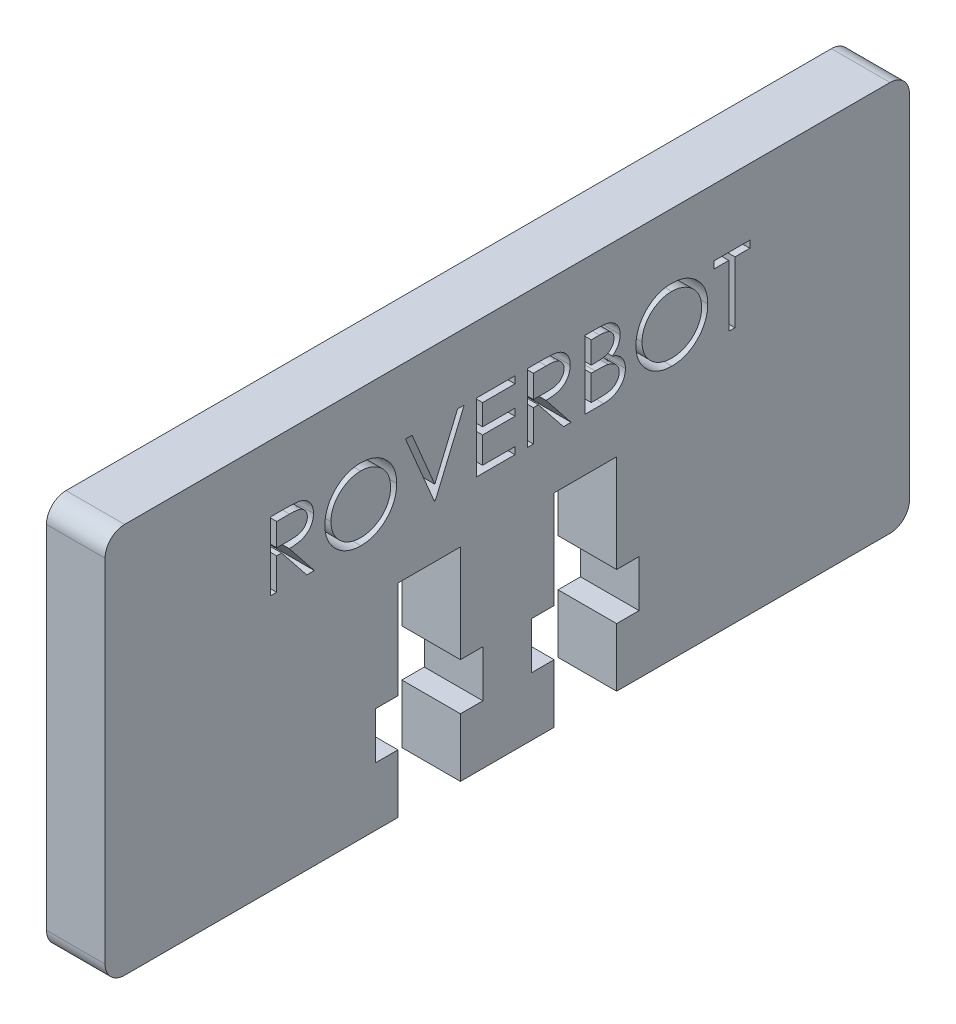
from build123d import *

# Parameters (mm, degrees)
BOSS_EXTRUDE1_DEPTH = 3
FILLET1_R           = 1
CUT_EXTRUDE1_DEPTH  = 4


with BuildPart() as part:
    # Sketch1 → Boss-Extrude1 (new body)
    with BuildSketch(Plane(origin=(0, 0, 0), x_dir=(0, 0, -1), z_dir=(1, 0, 0))):
        Polygon((-5.6, 0), (-5.6, 3), (-6.75, 3), (-6.75, 5.4), (-5.6, 5.4), (-5.6, 10.4), (-2.4, 10.4), (-2.4, 5.4), (-1.25, 5.4), (-1.25, 3), (-2.4, 3), (-2.4, 0), (2.4, 0), (2.4, 3), (1.25, 3), (1.25, 5.4), (2.4, 5.4), (2.4, 10.4), (5.6, 10.4), (5.6, 5.4), (6.75, 5.4), (6.75, 3), (5.6, 3), (5.6, 0), (20.6, 0), (20.6, 20), (-20.6, 20), (-20.6, 0), align=None)
    extrude(amount=BOSS_EXTRUDE1_DEPTH)

    # Fillet1
    fillet1_edges = [part.edges().sort_by_distance(p)[0] for p in [
        (1.5, 0, 20.6),
        (1.5, 20, 20.6),
        (1.5, 20, -20.6),
        (1.5, 0, -20.6),
    ]]
    fillet(fillet1_edges, radius=FILLET1_R)

    # Sketch2 → Cut-Extrude1 (cut, through all)
    with BuildSketch(Plane(origin=(3, 0, 0), x_dir=(0, 0, -1), z_dir=(1, 0, 0))):
        with BuildLine():
            Line((-12.124529254, 16.594452032), (-11.424108581, 16.594452032))
            add(Edge.make_bspline(
                [(-11.424108581, 16.594452032), (-11.377367453, 16.594296446), (-11.287619308, 16.593997704), (-11.159046038, 16.592331941), (-11.042218941, 16.587557585), (-10.937199102, 16.583449001), (-10.843988447, 16.57595706), (-10.762301156, 16.568796413), (-10.692513459, 16.559422752), (-10.650267607, 16.550717329), (-10.631139831, 16.54677575)],
                knots=[0, 0, 0, 0, 0.000140226, 0.00026925, 0.000385712, 0.000490995, 0.000584507, 0.000666202, 0.000736998, 0.000795574, 0.000795574, 0.000795574, 0.000795574], degree=3))
            add(Edge.make_bspline(
                [(-10.631139831, 16.54677575), (-10.605533207, 16.540448984), (-10.554866218, 16.527930421), (-10.481916152, 16.50147082), (-10.412401828, 16.470851195), (-10.346612003, 16.434887475), (-10.284876212, 16.393312695), (-10.226557901, 16.346844573), (-10.171392438, 16.295737367), (-10.121610808, 16.238702526), (-10.074671756, 16.178866016), (-10.03508313, 16.114162259), (-10.00095665, 16.046500732), (-9.973786133, 15.975193314), (-9.95190816, 15.900931542), (-9.93648192, 15.823042745), (-9.927230733, 15.74188177), (-9.926288877, 15.686523861), (-9.925811306, 15.658454436)],
                knots=[0, 0, 0, 0, 7.9081e-05, 0.000156475, 0.000232432, 0.000306798, 0.00038108, 0.000455429, 0.000530331, 0.000606314, 0.000682321, 0.000758201, 0.000833453, 0.000909362, 0.000986794, 0.001065445, 0.001147284, 0.001231465, 0.001231465, 0.001231465, 0.001231465], degree=3))
            add(Edge.make_bspline(
                [(-9.925811306, 15.658454436), (-9.927280304, 15.611819331), (-9.9301467, 15.520822163), (-9.956871803, 15.388761282), (-10.000648323, 15.265571967), (-10.060971612, 15.151409329), (-10.137791088, 15.048498684), (-10.230115879, 14.958108229), (-10.33799749, 14.882468316), (-10.438426806, 14.830015511), (-10.527141006, 14.796422603), (-10.600174319, 14.772786244), (-10.679841296, 14.754524279), (-10.765378631, 14.738164147), (-10.857142286, 14.725812452), (-10.954912326, 14.716765858), (-11.058758477, 14.711111809), (-11.130097547, 14.710269804), (-11.166796883, 14.709836647)],
                knots=[0, 0, 0, 0, 0.000139777, 0.000272741, 0.000402249, 0.000530843, 0.000658588, 0.000786009, 0.000916741, 0.001052522, 0.001124656, 0.001201155, 0.001282612, 0.001369656, 0.001462366, 0.001560247, 0.001664165, 0.001774261, 0.001774261, 0.001774261, 0.001774261], degree=3))
            Line((-11.166796883, 14.709836647), (-9.880939511, 13.094452032))
            Line((-9.880939511, 13.094452032), (-10.269360985, 13.094452032))
            Line((-10.269360985, 13.094452032), (-11.555218357, 14.709836647))
            Line((-11.555218357, 14.709836647), (-11.81042669, 14.709836647))
            Line((-11.81042669, 14.709836647), (-11.81042669, 13.094452032))
            Line((-11.81042669, 13.094452032), (-12.124529254, 13.094452032))
            Line((-12.124529254, 13.094452032), (-12.124529254, 16.594452032))
        make_face()
        with BuildLine():
            Line((-11.81042669, 16.235477673), (-11.81042669, 15.068811006))
            Line((-11.81042669, 15.068811006), (-11.16960137, 15.063903154))
            add(Edge.make_bspline(
                [(-11.16960137, 15.063903154), (-11.139681331, 15.063889917), (-11.081687774, 15.063864261), (-10.997787109, 15.067858037), (-10.919666997, 15.072401355), (-10.847626245, 15.079350701), (-10.78163267, 15.088306772), (-10.721719257, 15.099509757), (-10.667788205, 15.112561819), (-10.604889666, 15.132763445), (-10.534653135, 15.164769463), (-10.458321675, 15.211334962), (-10.393319337, 15.269904081), (-10.338401475, 15.336877537), (-10.294272043, 15.410513786), (-10.263159989, 15.489930155), (-10.243417547, 15.573121753), (-10.241089001, 15.630299861), (-10.23991387, 15.659155558)],
                knots=[0, 0, 0, 0, 8.9746e-05, 0.000173954, 0.000251933, 0.000324488, 0.000391021, 0.000451663, 0.000507268, 0.000557378, 0.000649639, 0.000738152, 0.000824558, 0.000910739, 0.000997194, 0.001080909, 0.00116578, 0.001252248, 0.001252248, 0.001252248, 0.001252248], degree=3))
            add(Edge.make_bspline(
                [(-10.23991387, 15.659155558), (-10.241115991, 15.687302131), (-10.243498156, 15.74307837), (-10.262946925, 15.82473428), (-10.295836306, 15.90180123), (-10.340158544, 15.973965715), (-10.394157699, 16.039471451), (-10.457475512, 16.095518604), (-10.528380707, 16.141768069), (-10.594651905, 16.171322449), (-10.653886118, 16.189442303), (-10.705315778, 16.202193466), (-10.763427255, 16.212437935), (-10.828502714, 16.220645996), (-10.900264345, 16.227700941), (-10.979074996, 16.232452719), (-11.064411776, 16.235266583), (-11.123558707, 16.235405672), (-11.15417669, 16.235477673)],
                knots=[0, 0, 0, 0, 8.4371e-05, 0.000167192, 0.000250141, 0.000334794, 0.000420435, 0.000503871, 0.000587493, 0.000673488, 0.0007205, 0.000773215, 0.000832351, 0.0008974, 0.000969955, 0.001048634, 0.001134217, 0.001226067, 0.001226067, 0.001226067, 0.001226067], degree=3))
            Line((-11.15417669, 16.235477673), (-11.81042669, 16.235477673))
        make_face(mode=Mode.SUBTRACT)
        with BuildLine():
            add(Edge.make_bspline(
                [(-7.52517028, 16.684195622), (-7.460362174, 16.682554142), (-7.333073707, 16.679330141), (-7.145998809, 16.654651038), (-6.967403714, 16.611955648), (-6.795833575, 16.555092665), (-6.633340599, 16.47923828), (-6.478701706, 16.387553132), (-6.332284833, 16.279076673), (-6.196063451, 16.154647446), (-6.071406501, 16.019263992), (-5.961580614, 15.874786082), (-5.869538321, 15.72208728), (-5.793952534, 15.561626449), (-5.734653924, 15.393766481), (-5.69373488, 15.217612478), (-5.66759673, 15.034305788), (-5.664540953, 14.909278924), (-5.662990793, 14.845854275)],
                knots=[0, 0, 0, 0, 0.000194393, 0.000381804, 0.00056479, 0.000744601, 0.000923091, 0.001101652, 0.001283106, 0.001468738, 0.001654324, 0.001834514, 0.002012231, 0.002188181, 0.002365797, 0.002545211, 0.002729936, 0.002920126, 0.002920126, 0.002920126, 0.002920126], degree=3))
            add(Edge.make_bspline(
                [(-5.662990793, 14.845854275), (-5.664540725, 14.782896829), (-5.667595822, 14.658800409), (-5.6937646, 14.476656964), (-5.734805599, 14.301566268), (-5.793401866, 14.133820615), (-5.868627344, 13.973243051), (-5.961282515, 13.820256098), (-6.070423726, 13.674809599), (-6.194630577, 13.538496934), (-6.330031619, 13.413499463), (-6.475261886, 13.304580588), (-6.627055206, 13.210856463), (-6.787364914, 13.136072789), (-6.954064951, 13.076300869), (-7.128647274, 13.035548239), (-7.310293828, 13.009261195), (-7.434164832, 13.006242679), (-7.497125408, 13.004708442)],
                knots=[0, 0, 0, 0, 0.000188789, 0.000372126, 0.000550857, 0.00072758, 0.000904164, 0.001081881, 0.001263191, 0.001448823, 0.00163441, 0.001815159, 0.001992641, 0.002168591, 0.002344885, 0.002522934, 0.002705576, 0.002894365, 0.002894365, 0.002894365, 0.002894365], degree=3))
            add(Edge.make_bspline(
                [(-7.497125408, 13.004708442), (-7.560549727, 13.006257829), (-7.685575943, 13.009312083), (-7.869112979, 13.035493488), (-8.045390722, 13.076434792), (-8.213905074, 13.134944228), (-8.374750003, 13.210561458), (-8.528240086, 13.302765838), (-8.673759233, 13.412172979), (-8.81010098, 13.536339553), (-8.934850178, 13.671511105), (-9.043609554, 13.81634536), (-9.135834667, 13.968000817), (-9.211197999, 14.126898341), (-9.270862459, 14.292269784), (-9.311567277, 14.465218261), (-9.337903229, 14.644757767), (-9.340938075, 14.767000665), (-9.342477972, 14.829027352)],
                knots=[0, 0, 0, 0, 0.00019019, 0.000374915, 0.000555011, 0.000732396, 0.00090898, 0.001087298, 0.001268608, 0.00145424, 0.001639827, 0.001819595, 0.001996712, 0.002171394, 0.002346367, 0.002523053, 0.002703612, 0.002889599, 0.002889599, 0.002889599, 0.002889599], degree=3))
            add(Edge.make_bspline(
                [(-9.342477972, 14.829027352), (-9.341943337, 14.870660022), (-9.340880811, 14.953400145), (-9.328089118, 15.076266745), (-9.309527417, 15.197157403), (-9.282925504, 15.315728351), (-9.248133837, 15.431689336), (-9.20708181, 15.545840098), (-9.156941965, 15.657023822), (-9.100261317, 15.765767214), (-9.036999509, 15.87037512), (-8.967123759, 15.969254703), (-8.893088391, 16.0632357), (-8.811924997, 16.149882704), (-8.726308552, 16.23171636), (-8.634850174, 16.307479077), (-8.538107929, 16.377854028), (-8.43566555, 16.441274369), (-8.330047275, 16.498633504), (-8.221170497, 16.547855355), (-8.110513925, 16.590101416), (-7.997559277, 16.624342241), (-7.882606505, 16.651374277), (-7.765404721, 16.669781631), (-7.646047294, 16.682605949), (-7.565635976, 16.683663451), (-7.52517028, 16.684195622)],
                knots=[0, 0, 0, 0, 0.000124849, 0.000248123, 0.000370193, 0.00049164, 0.000612319, 0.000733199, 0.000855287, 0.000977905, 0.001100913, 0.001221706, 0.001340948, 0.001459521, 0.001577551, 0.001696047, 0.001815534, 0.001936153, 0.002057243, 0.002175846, 0.002294342, 0.002412335, 0.002529682, 0.00264829, 0.002768075, 0.00288942, 0.00288942, 0.00288942, 0.00288942], degree=3))
        make_face()
        with BuildLine():
            add(Edge.make_bspline(
                [(-7.509745601, 16.325221263), (-7.542960234, 16.324816372), (-7.609071967, 16.324010463), (-7.707356503, 16.313394747), (-7.804348437, 16.298264858), (-7.900067799, 16.276683337), (-7.994114089, 16.247279285), (-8.08736393, 16.213438376), (-8.178966984, 16.172217286), (-8.268620842, 16.125644581), (-8.355535917, 16.074095661), (-8.437548618, 16.017123894), (-8.514871262, 15.956065339), (-8.587314529, 15.890777502), (-8.654665701, 15.8209279), (-8.718250402, 15.747575464), (-8.775519984, 15.668623573), (-8.828005561, 15.586213166), (-8.874973401, 15.500451585), (-8.916738756, 15.412241723), (-8.950902765, 15.320864036), (-8.978765141, 15.227309878), (-9.001864952, 15.131727419), (-9.016498876, 15.03339157), (-9.027231235, 14.932796458), (-9.027991081, 14.864814604), (-9.028375408, 14.830429596)],
                knots=[0, 0, 0, 0, 9.9599e-05, 0.000198245, 0.000296222, 0.00039402, 0.00049227, 0.000591646, 0.000691452, 0.000793368, 0.000894612, 0.000994383, 0.001092713, 0.00119001, 0.001286696, 0.001383657, 0.001480979, 0.001579008, 0.001676595, 0.001774142, 0.001871547, 0.001968922, 0.002066879, 0.00216624, 0.00226698, 0.002370083, 0.002370083, 0.002370083, 0.002370083], degree=3))
            add(Edge.make_bspline(
                [(-9.028375408, 14.830429596), (-9.027100546, 14.779867375), (-9.024592498, 14.680395845), (-9.002634928, 14.534627701), (-8.968812954, 14.394539415), (-8.918955587, 14.260897505), (-8.856604973, 14.132553223), (-8.779578083, 14.010645118), (-8.688318997, 13.895140243), (-8.58465547, 13.786844975), (-8.471332764, 13.68799917), (-8.351000034, 13.601235762), (-8.224946426, 13.527825512), (-8.092843224, 13.468020439), (-7.955395685, 13.420630702), (-7.811718134, 13.388152071), (-7.662767674, 13.366776615), (-7.561237019, 13.364723859), (-7.509745601, 13.363682801)],
                knots=[0, 0, 0, 0, 0.000151605, 0.000298253, 0.000441263, 0.000583229, 0.000725274, 0.000868635, 0.001014928, 0.001166177, 0.001317744, 0.00146543, 0.001610576, 0.001754594, 0.001899821, 0.002045914, 0.002195936, 0.002350312, 0.002350312, 0.002350312, 0.002350312], degree=3))
            add(Edge.make_bspline(
                [(-7.509745601, 13.363682801), (-7.475136099, 13.364158305), (-7.406495063, 13.365101373), (-7.30439954, 13.37460005), (-7.204143329, 13.38983192), (-7.105867049, 13.411762575), (-7.009682237, 13.439209782), (-6.915187434, 13.47181751), (-6.823389144, 13.512498713), (-6.733129306, 13.557446665), (-6.646733064, 13.608686822), (-6.564257532, 13.663724972), (-6.487781552, 13.724693593), (-6.415392481, 13.789011405), (-6.347764792, 13.857975253), (-6.285355808, 13.931495475), (-6.228375675, 14.010036132), (-6.175910029, 14.092321538), (-6.129106766, 14.178317791), (-6.088327667, 14.266847469), (-6.053731551, 14.357692578), (-6.025803046, 14.45098415), (-6.003917585, 14.546544998), (-5.988837665, 14.644503076), (-5.978289226, 14.744662419), (-5.977494149, 14.812406275), (-5.977093357, 14.846555397)],
                knots=[0, 0, 0, 0, 0.000103804, 0.000205874, 0.000307314, 0.000407849, 0.000507719, 0.000607281, 0.000707445, 0.000808723, 0.000909609, 0.001008589, 0.001105934, 0.001202762, 0.001298946, 0.001395452, 0.001491794, 0.001589823, 0.001688026, 0.001785277, 0.001882027, 0.001979402, 0.0020772, 0.002175869, 0.002276609, 0.002379011, 0.002379011, 0.002379011, 0.002379011], degree=3))
            add(Edge.make_bspline(
                [(-5.977093357, 14.846555397), (-5.97749447, 14.880470902), (-5.978290151, 14.947748552), (-5.988832626, 15.04720937), (-6.003933516, 15.144462582), (-6.025696224, 15.239126385), (-6.053746378, 15.33122491), (-6.088333709, 15.420671657), (-6.129119008, 15.507799852), (-6.175927232, 15.592394149), (-6.228543056, 15.673568887), (-6.286037299, 15.7511713), (-6.349402647, 15.823744041), (-6.416828672, 15.893078735), (-6.489999558, 15.957696625), (-6.568583852, 16.017619146), (-6.651627529, 16.07429242), (-6.739554765, 16.125417982), (-6.830298719, 16.172632214), (-6.923412677, 16.213083217), (-7.017841776, 16.247455337), (-7.113345889, 16.276772302), (-7.210728867, 16.298180332), (-7.309332696, 16.313408382), (-7.409020954, 16.324006768), (-7.476064174, 16.324815146), (-7.509745601, 16.325221263)],
                knots=[0, 0, 0, 0, 0.000101701, 0.000201743, 0.00029972, 0.000396835, 0.000492868, 0.000588308, 0.000684288, 0.000781261, 0.000878109, 0.000974304, 0.001070733, 0.001166917, 0.001264269, 0.001363274, 0.001463228, 0.001565678, 0.001668217, 0.001769947, 0.001869982, 0.001969573, 0.002069423, 0.002168785, 0.002268827, 0.002369827, 0.002369827, 0.002369827, 0.002369827], degree=3))
        make_face(mode=Mode.SUBTRACT)
        Polygon((-5.214272844, 16.594452032), (-4.877734383, 16.594452032), (-3.711067716, 13.836238891), (-2.544401049, 16.594452032), (-2.207862588, 16.594452032), (-3.688631819, 13.094452032), (-3.733503613, 13.094452032), align=None)
        Polygon((-1.57965746, 16.594452032), (0.394701515, 16.594452032), (0.394701515, 16.235477673), (-1.265554895, 16.235477673), (-1.265554895, 15.158554596), (0.394701515, 15.158554596), (0.394701515, 14.799580237), (-1.265554895, 14.799580237), (-1.265554895, 13.453426391), (0.394701515, 13.453426391), (0.394701515, 13.094452032), (-1.57965746, 13.094452032), align=None)
        with BuildLine():
            Line((1.022906643, 16.594452032), (1.723327316, 16.594452032))
            add(Edge.make_bspline(
                [(1.723327316, 16.594452032), (1.770068445, 16.594296446), (1.859816589, 16.593997704), (1.988389859, 16.592331941), (2.105216956, 16.587557585), (2.210236796, 16.583449001), (2.303447451, 16.57595706), (2.385134741, 16.568796413), (2.454922439, 16.559422752), (2.49716829, 16.550717329), (2.516296066, 16.54677575)],
                knots=[0, 0, 0, 0, 0.000140226, 0.00026925, 0.000385712, 0.000490995, 0.000584507, 0.000666202, 0.000736998, 0.000795574, 0.000795574, 0.000795574, 0.000795574], degree=3))
            add(Edge.make_bspline(
                [(2.516296066, 16.54677575), (2.54190269, 16.540448984), (2.59256968, 16.527930421), (2.665519746, 16.50147082), (2.73503407, 16.470851195), (2.800823894, 16.434887475), (2.862559685, 16.393312695), (2.920877996, 16.346844573), (2.976043459, 16.295737367), (3.02582509, 16.238702526), (3.072764141, 16.178866016), (3.112352768, 16.114162259), (3.146479247, 16.046500732), (3.173649764, 15.975193314), (3.195527738, 15.900931542), (3.210953977, 15.823042745), (3.220205165, 15.74188177), (3.22114702, 15.686523861), (3.221624592, 15.658454436)],
                knots=[0, 0, 0, 0, 7.9081e-05, 0.000156475, 0.000232432, 0.000306798, 0.00038108, 0.000455429, 0.000530331, 0.000606314, 0.000682321, 0.000758201, 0.000833453, 0.000909362, 0.000986794, 0.001065445, 0.001147284, 0.001231465, 0.001231465, 0.001231465, 0.001231465], degree=3))
            add(Edge.make_bspline(
                [(3.221624592, 15.658454436), (3.220155594, 15.611819331), (3.217289198, 15.520822163), (3.190564094, 15.388761282), (3.146787574, 15.265571967), (3.086464285, 15.151409329), (3.00964481, 15.048498684), (2.917320019, 14.958108229), (2.809438407, 14.882468316), (2.709009091, 14.830015511), (2.620294891, 14.796422603), (2.547261579, 14.772786244), (2.467594601, 14.754524279), (2.382057267, 14.738164147), (2.290293611, 14.725812452), (2.192523572, 14.716765858), (2.08867742, 14.711111809), (2.017338351, 14.710269804), (1.980639015, 14.709836647)],
                knots=[0, 0, 0, 0, 0.000139777, 0.000272741, 0.000402249, 0.000530843, 0.000658588, 0.000786009, 0.000916741, 0.001052522, 0.001124656, 0.001201155, 0.001282612, 0.001369656, 0.001462366, 0.001560247, 0.001664165, 0.001774261, 0.001774261, 0.001774261, 0.001774261], degree=3))
            Line((1.980639015, 14.709836647), (3.266496387, 13.094452032))
            Line((3.266496387, 13.094452032), (2.878074912, 13.094452032))
            Line((2.878074912, 13.094452032), (1.59221754, 14.709836647))
            Line((1.59221754, 14.709836647), (1.337009207, 14.709836647))
            Line((1.337009207, 14.709836647), (1.337009207, 13.094452032))
            Line((1.337009207, 13.094452032), (1.022906643, 13.094452032))
            Line((1.022906643, 13.094452032), (1.022906643, 16.594452032))
        make_face()
        with BuildLine():
            Line((1.337009207, 16.235477673), (1.337009207, 15.068811006))
            Line((1.337009207, 15.068811006), (1.977834528, 15.063903154))
            add(Edge.make_bspline(
                [(1.977834528, 15.063903154), (2.007754567, 15.063889917), (2.065748124, 15.063864261), (2.149648788, 15.067858037), (2.2277689, 15.072401355), (2.299809652, 15.079350701), (2.365803228, 15.088306772), (2.425716641, 15.099509757), (2.479647693, 15.112561819), (2.542546231, 15.132763445), (2.612782763, 15.164769463), (2.689114222, 15.211334962), (2.75411656, 15.269904081), (2.809034422, 15.336877537), (2.853163854, 15.410513786), (2.884275908, 15.489930155), (2.904018351, 15.573121753), (2.906346896, 15.630299861), (2.907522028, 15.659155558)],
                knots=[0, 0, 0, 0, 8.9746e-05, 0.000173954, 0.000251933, 0.000324488, 0.000391021, 0.000451663, 0.000507268, 0.000557378, 0.000649639, 0.000738152, 0.000824558, 0.000910739, 0.000997194, 0.001080909, 0.00116578, 0.001252248, 0.001252248, 0.001252248, 0.001252248], degree=3))
            add(Edge.make_bspline(
                [(2.907522028, 15.659155558), (2.906319907, 15.687302131), (2.903937741, 15.74307837), (2.884488973, 15.82473428), (2.851599591, 15.90180123), (2.807277353, 15.973965715), (2.753278198, 16.039471451), (2.689960386, 16.095518604), (2.619055191, 16.141768069), (2.552783992, 16.171322449), (2.49354978, 16.189442303), (2.44212012, 16.202193466), (2.384008642, 16.212437935), (2.318933183, 16.220645996), (2.247171553, 16.227700941), (2.168360901, 16.232452719), (2.083024121, 16.235266583), (2.02387719, 16.235405672), (1.993259207, 16.235477673)],
                knots=[0, 0, 0, 0, 8.4371e-05, 0.000167192, 0.000250141, 0.000334794, 0.000420435, 0.000503871, 0.000587493, 0.000673488, 0.0007205, 0.000773215, 0.000832351, 0.0008974, 0.000969955, 0.001048634, 0.001134217, 0.001226067, 0.001226067, 0.001226067, 0.001226067], degree=3))
            Line((1.993259207, 16.235477673), (1.337009207, 16.235477673))
        make_face(mode=Mode.SUBTRACT)
        with BuildLine():
            Line((3.984445105, 16.594452032), (4.667337733, 16.594452032))
            add(Edge.make_bspline(
                [(4.667337733, 16.594452032), (4.700766211, 16.594276281), (4.765558921, 16.593935633), (4.859778363, 16.588652502), (4.948027174, 16.581448832), (5.030330946, 16.57001874), (5.106651648, 16.556226963), (5.177219286, 16.539525147), (5.241809458, 16.519498533), (5.318922194, 16.487652252), (5.406842855, 16.440329083), (5.502041248, 16.370400518), (5.583445487, 16.284868055), (5.653631805, 16.1883854), (5.709432924, 16.082249628), (5.749802221, 15.968990439), (5.775360097, 15.850068697), (5.777988531, 15.768425519), (5.779316899, 15.727164372)],
                knots=[0, 0, 0, 0, 0.00010027, 0.000194349, 0.000283026, 0.000365821, 0.000443519, 0.000515622, 0.000583254, 0.00064614, 0.000765662, 0.000881909, 0.000998927, 0.001118415, 0.001238844, 0.00135727, 0.001478274, 0.001601912, 0.001601912, 0.001601912, 0.001601912], degree=3))
            add(Edge.make_bspline(
                [(5.779316899, 15.727164372), (5.778223681, 15.688511816), (5.776075404, 15.612555899), (5.755532644, 15.50146179), (5.723371976, 15.395710571), (5.678666727, 15.295688185), (5.62056473, 15.203654572), (5.551706412, 15.118867306), (5.468629609, 15.044916249), (5.406386369, 15.003573347), (5.374769624, 14.982573025)],
                knots=[0, 0, 0, 0, 0.000115857, 0.00022767, 0.000337672, 0.000446877, 0.000555233, 0.000663318, 0.000773539, 0.000887324, 0.000887324, 0.000887324, 0.000887324], degree=3))
            add(Edge.make_bspline(
                [(5.374769624, 14.982573025), (5.414530051, 14.967308027), (5.490601599, 14.938102302), (5.595287611, 14.886466838), (5.685482456, 14.830304728), (5.761879602, 14.768972878), (5.827217257, 14.702864067), (5.884270199, 14.631008953), (5.932951573, 14.552470195), (5.974664496, 14.468066659), (6.007213252, 14.378660191), (6.031589157, 14.285089415), (6.045556606, 14.18768986), (6.047544247, 14.12140448), (6.048547669, 14.087941615)],
                knots=[0, 0, 0, 0, 0.000127722, 0.000244363, 0.000349599, 0.000445847, 0.000537565, 0.000627901, 0.000720503, 0.000814257, 0.000909859, 0.001005428, 0.001103887, 0.001204268, 0.001204268, 0.001204268, 0.001204268], degree=3))
            add(Edge.make_bspline(
                [(6.048547669, 14.087941615), (6.047570823, 14.053774743), (6.045648851, 13.986550465), (6.031468879, 13.88779533), (6.007459772, 13.793420384), (5.974388626, 13.702815201), (5.931226311, 13.616155067), (5.878698347, 13.533341803), (5.816066783, 13.455207472), (5.746003914, 13.380883849), (5.666741769, 13.314056062), (5.581226014, 13.254540355), (5.488379694, 13.205594293), (5.3897277, 13.164478271), (5.284163384, 13.133071073), (5.172160776, 13.111098499), (5.053816474, 13.096293462), (4.972606723, 13.095076257), (4.930959528, 13.094452032)],
                knots=[0, 0, 0, 0, 0.000102481, 0.000201635, 0.000298562, 0.000394165, 0.000490425, 0.000588455, 0.000687769, 0.000790423, 0.000894381, 0.000998232, 0.001102369, 0.001208616, 0.001318415, 0.001432129, 0.001550749, 0.00167562, 0.00167562, 0.00167562, 0.00167562], degree=3))
            Line((4.930959528, 13.094452032), (3.984445105, 13.094452032))
            Line((3.984445105, 13.094452032), (3.984445105, 16.594452032))
        make_face()
        with BuildLine():
            Line((4.298547669, 16.235477673), (4.298547669, 15.113682801))
            Line((4.298547669, 15.113682801), (4.509585329, 15.113682801))
            add(Edge.make_bspline(
                [(4.509585329, 15.113682801), (4.540434124, 15.114082724), (4.600040284, 15.114855457), (4.68636018, 15.117068974), (4.766485198, 15.123267017), (4.840277031, 15.129463279), (4.907619475, 15.139537867), (4.968363337, 15.15152999), (5.023461934, 15.164212895), (5.087001479, 15.185782382), (5.159074428, 15.217660057), (5.235907532, 15.267131893), (5.303642001, 15.326056246), (5.360839189, 15.394047208), (5.40765066, 15.468913394), (5.440164375, 15.549460275), (5.462211659, 15.633680407), (5.46420319, 15.691498659), (5.465214335, 15.720854275)],
                knots=[0, 0, 0, 0, 9.2559e-05, 0.000178842, 0.000258967, 0.000333616, 0.000400942, 0.000463093, 0.000519379, 0.000570374, 0.000664201, 0.000755025, 0.000843472, 0.000932526, 0.001020669, 0.001107124, 0.001192318, 0.001280185, 0.001280185, 0.001280185, 0.001280185], degree=3))
            add(Edge.make_bspline(
                [(5.465214335, 15.720854275), (5.464688155, 15.740280047), (5.463655995, 15.778385819), (5.455202693, 15.833935173), (5.440835118, 15.886178926), (5.422380825, 15.935833036), (5.396592136, 15.981344886), (5.366228673, 16.024288082), (5.329542983, 16.0632002), (5.28778567, 16.099569699), (5.239777047, 16.131814227), (5.185545755, 16.16005499), (5.124358078, 16.182795766), (5.057245223, 16.202711919), (4.983174136, 16.216700213), (4.902999582, 16.2283536), (4.816064863, 16.234286342), (4.755919761, 16.235071705), (4.72482972, 16.235477673)],
                knots=[0, 0, 0, 0, 5.8261e-05, 0.000114285, 0.000168029, 0.000220632, 0.000272728, 0.000324483, 0.000378062, 0.000432741, 0.000490301, 0.000551137, 0.000615721, 0.000685833, 0.000760908, 0.00084162, 0.000928788, 0.00102206, 0.00102206, 0.00102206, 0.00102206], degree=3))
            Line((4.72482972, 16.235477673), (4.298547669, 16.235477673))
        make_face(mode=Mode.SUBTRACT)
        with BuildLine():
            Line((4.298547669, 14.754708442), (4.298547669, 13.453426391))
            Line((4.298547669, 13.453426391), (4.745863374, 13.453426391))
            add(Edge.make_bspline(
                [(4.745863374, 13.453426391), (4.7778823, 13.453810138), (4.839594558, 13.454549761), (4.928695788, 13.456964315), (5.011278892, 13.462456591), (5.086967028, 13.471102441), (5.156577481, 13.48048089), (5.219275184, 13.493092171), (5.275568377, 13.507541131), (5.340842685, 13.529875304), (5.414346193, 13.564571774), (5.493557049, 13.616886001), (5.563983268, 13.679209309), (5.623788527, 13.751340223), (5.672801515, 13.82977155), (5.70845697, 13.9129169), (5.730447827, 13.999402427), (5.733109996, 14.05836914), (5.734445105, 14.087941615)],
                knots=[0, 0, 0, 0, 9.6064e-05, 0.000185151, 0.000267373, 0.000344257, 0.000413665, 0.000478015, 0.000536005, 0.000587888, 0.000684801, 0.000778918, 0.000871787, 0.000965866, 0.001059062, 0.00114827, 0.001236355, 0.001324974, 0.001324974, 0.001324974, 0.001324974], degree=3))
            add(Edge.make_bspline(
                [(5.734445105, 14.087941615), (5.734169, 14.106434956), (5.733621245, 14.143123337), (5.72536063, 14.197039157), (5.71334676, 14.24926503), (5.697815327, 14.29994277), (5.675195859, 14.348156147), (5.648789314, 14.394858706), (5.617827913, 14.440112186), (5.569583747, 14.497324439), (5.499411762, 14.563241452), (5.399704987, 14.627778954), (5.286332689, 14.679826761), (5.204105196, 14.701926238), (5.161628598, 14.713342256)],
                knots=[0, 0, 0, 0, 5.5429e-05, 0.000109963, 0.000163198, 0.000216191, 0.000268588, 0.000322593, 0.000377046, 0.000432793, 0.000546889, 0.000664343, 0.000787646, 0.000919405, 0.000919405, 0.000919405, 0.000919405], degree=3))
            add(Edge.make_bspline(
                [(5.161628598, 14.713342256), (5.144599502, 14.71679734), (5.10767691, 14.724288675), (5.047469329, 14.732196378), (4.978733461, 14.739241438), (4.901310583, 14.744452596), (4.815102742, 14.749839139), (4.719925824, 14.75193396), (4.616168509, 14.754433221), (4.544176137, 14.754614355), (4.506780842, 14.754708442)],
                knots=[0, 0, 0, 0, 5.2115e-05, 0.000112995, 0.000182062, 0.000259389, 0.000345767, 0.00044116, 0.000544948, 0.000657129, 0.000657129, 0.000657129, 0.000657129], degree=3))
            Line((4.506780842, 14.754708442), (4.298547669, 14.754708442))
        make_face(mode=Mode.SUBTRACT)
        with BuildLine():
            add(Edge.make_bspline(
                [(8.404316899, 16.684195622), (8.469125005, 16.682554142), (8.596413472, 16.679330141), (8.78348837, 16.654651038), (8.962083465, 16.611955648), (9.133653604, 16.555092665), (9.296146581, 16.47923828), (9.450785473, 16.387553132), (9.597202347, 16.279076673), (9.733423728, 16.154647446), (9.858080679, 16.019263992), (9.967906565, 15.874786082), (10.059948859, 15.72208728), (10.135534646, 15.561626449), (10.194833256, 15.393766481), (10.235752299, 15.217612478), (10.261890449, 15.034305788), (10.264946227, 14.909278924), (10.266496387, 14.845854275)],
                knots=[0, 0, 0, 0, 0.000194393, 0.000381804, 0.00056479, 0.000744601, 0.000923091, 0.001101652, 0.001283106, 0.001468738, 0.001654324, 0.001834514, 0.002012231, 0.002188181, 0.002365797, 0.002545211, 0.002729936, 0.002920126, 0.002920126, 0.002920126, 0.002920126], degree=3))
            add(Edge.make_bspline(
                [(10.266496387, 14.845854275), (10.264946454, 14.782896829), (10.261891357, 14.658800409), (10.23572258, 14.476656964), (10.19468158, 14.301566268), (10.136085314, 14.133820615), (10.060859835, 13.973243051), (9.968204664, 13.820256098), (9.859063453, 13.674809599), (9.734856602, 13.538496934), (9.59945556, 13.413499463), (9.454225294, 13.304580588), (9.302431974, 13.210856463), (9.142122266, 13.136072789), (8.975422229, 13.076300869), (8.800839906, 13.035548239), (8.619193352, 13.009261195), (8.495322348, 13.006242679), (8.432361771, 13.004708442)],
                knots=[0, 0, 0, 0, 0.000188789, 0.000372126, 0.000550857, 0.00072758, 0.000904164, 0.001081881, 0.001263191, 0.001448823, 0.00163441, 0.001815159, 0.001992641, 0.002168591, 0.002344885, 0.002522934, 0.002705576, 0.002894365, 0.002894365, 0.002894365, 0.002894365], degree=3))
            add(Edge.make_bspline(
                [(8.432361771, 13.004708442), (8.368937452, 13.006257829), (8.243911236, 13.009312083), (8.060374201, 13.035493488), (7.884096457, 13.076434792), (7.715582106, 13.134944228), (7.554737176, 13.210561458), (7.401247094, 13.302765838), (7.255727946, 13.412172979), (7.1193862, 13.536339553), (6.994637002, 13.671511105), (6.885877626, 13.81634536), (6.793652513, 13.968000817), (6.71828918, 14.126898341), (6.658624721, 14.292269784), (6.617919903, 14.465218261), (6.591583951, 14.644757767), (6.588549104, 14.767000665), (6.587009207, 14.829027352)],
                knots=[0, 0, 0, 0, 0.00019019, 0.000374915, 0.000555011, 0.000732396, 0.00090898, 0.001087298, 0.001268608, 0.00145424, 0.001639827, 0.001819595, 0.001996712, 0.002171394, 0.002346367, 0.002523053, 0.002703612, 0.002889599, 0.002889599, 0.002889599, 0.002889599], degree=3))
            add(Edge.make_bspline(
                [(6.587009207, 14.829027352), (6.587543843, 14.870660022), (6.588606369, 14.953400145), (6.601398061, 15.076266745), (6.619959763, 15.197157403), (6.646561675, 15.315728351), (6.681353342, 15.431689336), (6.72240537, 15.545840098), (6.772545215, 15.657023822), (6.829225863, 15.765767214), (6.892487671, 15.87037512), (6.96236342, 15.969254703), (7.036398789, 16.0632357), (7.117562183, 16.149882704), (7.203178628, 16.23171636), (7.294637006, 16.307479077), (7.39137925, 16.377854028), (7.49382163, 16.441274369), (7.599439905, 16.498633504), (7.708316683, 16.547855355), (7.818973254, 16.590101416), (7.931927902, 16.624342241), (8.046880674, 16.651374277), (8.164082459, 16.669781631), (8.283439885, 16.682605949), (8.363851204, 16.683663451), (8.404316899, 16.684195622)],
                knots=[0, 0, 0, 0, 0.000124849, 0.000248123, 0.000370193, 0.00049164, 0.000612319, 0.000733199, 0.000855287, 0.000977905, 0.001100913, 0.001221706, 0.001340948, 0.001459521, 0.001577551, 0.001696047, 0.001815534, 0.001936153, 0.002057243, 0.002175846, 0.002294342, 0.002412335, 0.002529682, 0.00264829, 0.002768075, 0.00288942, 0.00288942, 0.00288942, 0.00288942], degree=3))
        make_face()
        with BuildLine():
            add(Edge.make_bspline(
                [(8.419741579, 16.325221263), (8.386526945, 16.324816372), (8.320415212, 16.324010463), (8.222130676, 16.313394747), (8.125138742, 16.298264858), (8.02941938, 16.276683337), (7.935373091, 16.247279285), (7.84212325, 16.213438376), (7.750520196, 16.172217286), (7.660866338, 16.125644581), (7.573951263, 16.074095661), (7.491938561, 16.017123894), (7.414615917, 15.956065339), (7.342172651, 15.890777502), (7.274821478, 15.8209279), (7.211236777, 15.747575464), (7.153967195, 15.668623573), (7.101481619, 15.586213166), (7.054513778, 15.500451585), (7.012748424, 15.412241723), (6.978584415, 15.320864036), (6.950722038, 15.227309878), (6.927622228, 15.131727419), (6.912988304, 15.03339157), (6.902255944, 14.932796458), (6.901496099, 14.864814604), (6.901111771, 14.830429596)],
                knots=[0, 0, 0, 0, 9.9599e-05, 0.000198245, 0.000296222, 0.00039402, 0.00049227, 0.000591646, 0.000691452, 0.000793368, 0.000894612, 0.000994383, 0.001092713, 0.00119001, 0.001286696, 0.001383657, 0.001480979, 0.001579008, 0.001676595, 0.001774142, 0.001871547, 0.001968922, 0.002066879, 0.00216624, 0.00226698, 0.002370083, 0.002370083, 0.002370083, 0.002370083], degree=3))
            add(Edge.make_bspline(
                [(6.901111771, 14.830429596), (6.902386633, 14.779867375), (6.904894681, 14.680395845), (6.926852251, 14.534627701), (6.960674226, 14.394539415), (7.010531592, 14.260897505), (7.072882207, 14.132553223), (7.149909097, 14.010645118), (7.241168183, 13.895140243), (7.344831709, 13.786844975), (7.458154416, 13.68799917), (7.578487146, 13.601235762), (7.704540753, 13.527825512), (7.836643956, 13.468020439), (7.974091495, 13.420630702), (8.117769046, 13.388152071), (8.266719506, 13.366776615), (8.368250161, 13.364723859), (8.419741579, 13.363682801)],
                knots=[0, 0, 0, 0, 0.000151605, 0.000298253, 0.000441263, 0.000583229, 0.000725274, 0.000868635, 0.001014928, 0.001166177, 0.001317744, 0.00146543, 0.001610576, 0.001754594, 0.001899821, 0.002045914, 0.002195936, 0.002350312, 0.002350312, 0.002350312, 0.002350312], degree=3))
            add(Edge.make_bspline(
                [(8.419741579, 13.363682801), (8.454351081, 13.364158305), (8.522992117, 13.365101373), (8.625087639, 13.37460005), (8.725343851, 13.38983192), (8.823620131, 13.411762575), (8.919804942, 13.439209782), (9.014299745, 13.47181751), (9.106098036, 13.512498713), (9.196357873, 13.557446665), (9.282754115, 13.608686822), (9.365229647, 13.663724972), (9.441705627, 13.724693593), (9.514094699, 13.789011405), (9.581722388, 13.857975253), (9.644131372, 13.931495475), (9.701111504, 14.010036132), (9.753577151, 14.092321538), (9.800380413, 14.178317791), (9.841159513, 14.266847469), (9.875755628, 14.357692578), (9.903684133, 14.45098415), (9.925569595, 14.546544998), (9.940649515, 14.644503076), (9.951197953, 14.744662419), (9.951993031, 14.812406275), (9.952393822, 14.846555397)],
                knots=[0, 0, 0, 0, 0.000103804, 0.000205874, 0.000307314, 0.000407849, 0.000507719, 0.000607281, 0.000707445, 0.000808723, 0.000909609, 0.001008589, 0.001105934, 0.001202762, 0.001298946, 0.001395452, 0.001491794, 0.001589823, 0.001688026, 0.001785277, 0.001882027, 0.001979402, 0.0020772, 0.002175869, 0.002276609, 0.002379011, 0.002379011, 0.002379011, 0.002379011], degree=3))
            add(Edge.make_bspline(
                [(9.952393822, 14.846555397), (9.95199271, 14.880470902), (9.951197028, 14.947748552), (9.940654553, 15.04720937), (9.925553663, 15.144462582), (9.903790955, 15.239126385), (9.875740801, 15.33122491), (9.841153471, 15.420671657), (9.800368171, 15.507799852), (9.753559947, 15.592394149), (9.700944124, 15.673568887), (9.64344988, 15.7511713), (9.580084532, 15.823744041), (9.512658507, 15.893078735), (9.439487622, 15.957696625), (9.360903328, 16.017619146), (9.27785965, 16.07429242), (9.189932415, 16.125417982), (9.099188461, 16.172632214), (9.006074503, 16.213083217), (8.911645403, 16.247455337), (8.816141291, 16.276772302), (8.718758313, 16.298180332), (8.620154484, 16.313408382), (8.520466225, 16.324006768), (8.453423005, 16.324815146), (8.419741579, 16.325221263)],
                knots=[0, 0, 0, 0, 0.000101701, 0.000201743, 0.00029972, 0.000396835, 0.000492868, 0.000588308, 0.000684288, 0.000781261, 0.000878109, 0.000974304, 0.001070733, 0.001166917, 0.001264269, 0.001363274, 0.001463228, 0.001565678, 0.001668217, 0.001769947, 0.001869982, 0.001969573, 0.002069423, 0.002168785, 0.002268827, 0.002369827, 0.002369827, 0.002369827, 0.002369827], degree=3))
        make_face(mode=Mode.SUBTRACT)
        Polygon((10.580598951, 16.235477673), (10.580598951, 16.594452032), (12.42034254, 16.594452032), (12.42034254, 16.235477673), (11.657522028, 16.235477673), (11.657522028, 13.094452032), (11.343419464, 13.094452032), (11.343419464, 16.235477673), align=None)
    extrude(amount=-CUT_EXTRUDE1_DEPTH, mode=Mode.SUBTRACT)


solid = part.part
